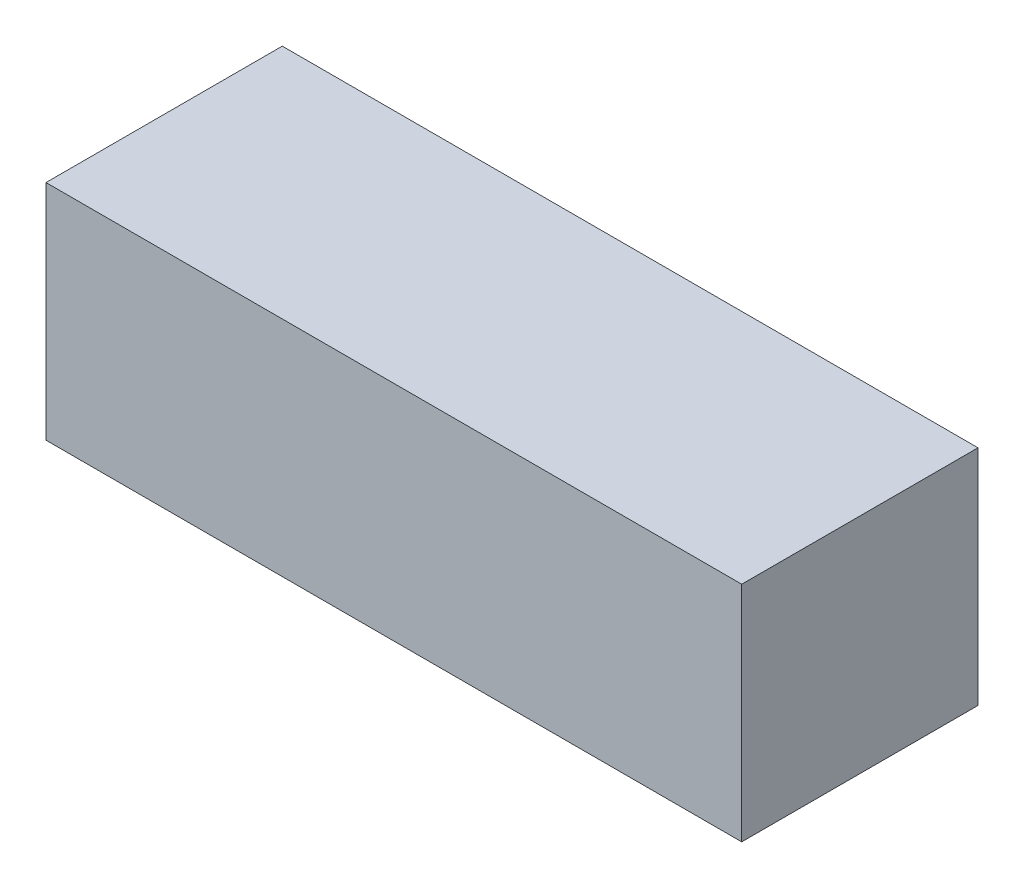
from build123d import *

# Parameters (mm, degrees)
SKETCH1_W           = 18
SKETCH1_H           = 17
BOSS_EXTRUDE1_DEPTH = 53


with BuildPart() as part:
    # Sketch1 → Boss-Extrude1 (new body)
    with BuildSketch(Plane(origin=(0, 0, 0), x_dir=(0, 0, -1), z_dir=(1, 0, 0))):
        Rectangle(SKETCH1_W, SKETCH1_H)
    extrude(amount=BOSS_EXTRUDE1_DEPTH)


solid = part.part
